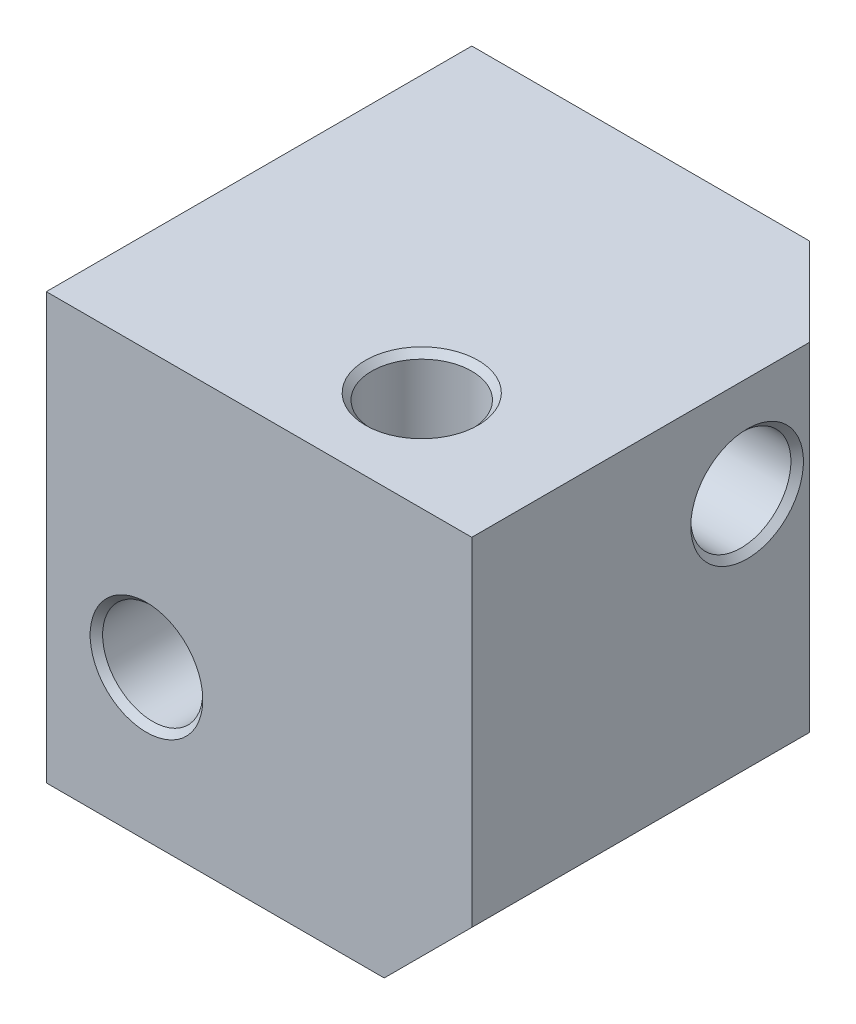
from build123d import *

# Parameters (mm, degrees)
SKETCH_1_W      = 17
SKETCH_1_H      = 17
EXTRUDE_1_DEPTH = 17
CHAMFER_1_SIZE  = 3.5


with BuildPart() as part:
    # Эскиз1 → Бобышка-Вытянуть1 (new body)
    with BuildSketch(Plane.XY):
        with Locations((8.5, 8.5)):
            Rectangle(SKETCH_1_W, SKETCH_1_H)
    extrude(amount=EXTRUDE_1_DEPTH)

    # Эскиз2 → Отверстие обработанное метчиком M4x0.71 (revolve, cut)
    with BuildSketch(Plane(origin=(11, 17, 13), x_dir=(0, 0, 1), z_dir=(1, 0, 0))):
        Polygon((0, 0), (0, 17), (2.25, 17), (2, 16.75), (2, 0.25), (2.25, 0), align=None)
    revolve(axis=Axis((11, 23.35, 13), (0, -1, 0)), mode=Mode.SUBTRACT)

    # Эскиз2 at point 2 (carried to point 2, square into its face) → Отверстие обработанное метчиком M4x0.71 at 2 (revolve, cut)
    with BuildSketch(Plane(origin=(4, 6, 17), x_dir=(0, -1, 0), z_dir=(1, 0, 0))):
        Polygon((0, 0), (0, 17), (2.25, 17), (2, 16.75), (2, 0.25), (2.25, 0), align=None)
    revolve(axis=Axis((4, 6, 23.35), (0, 0, -1)), mode=Mode.SUBTRACT)

    # Эскиз2 at point 3 (carried to point 3, square into its face) → Отверстие обработанное метчиком M4x0.71 at 3 (revolve, cut)
    with BuildSketch(Plane(origin=(0, 13, 6), x_dir=(0, 0, 1), z_dir=(0, 1, 0))):
        Polygon((0, 0), (0, 17), (2.25, 17), (2, 16.75), (2, 0.25), (2.25, 0), align=None)
    revolve(axis=Axis((-6.35, 13, 6), (1, 0, 0)), mode=Mode.SUBTRACT)

    # Фаска1
    chamfer_1_edges = [part.edges().sort_by_distance(p)[0] for p in [
        (17, 8.5, 0),
        (8.5, 0, 0),
        (17, 0, 8.5),
    ]]
    chamfer(chamfer_1_edges, length=CHAMFER_1_SIZE)


solid = part.part
